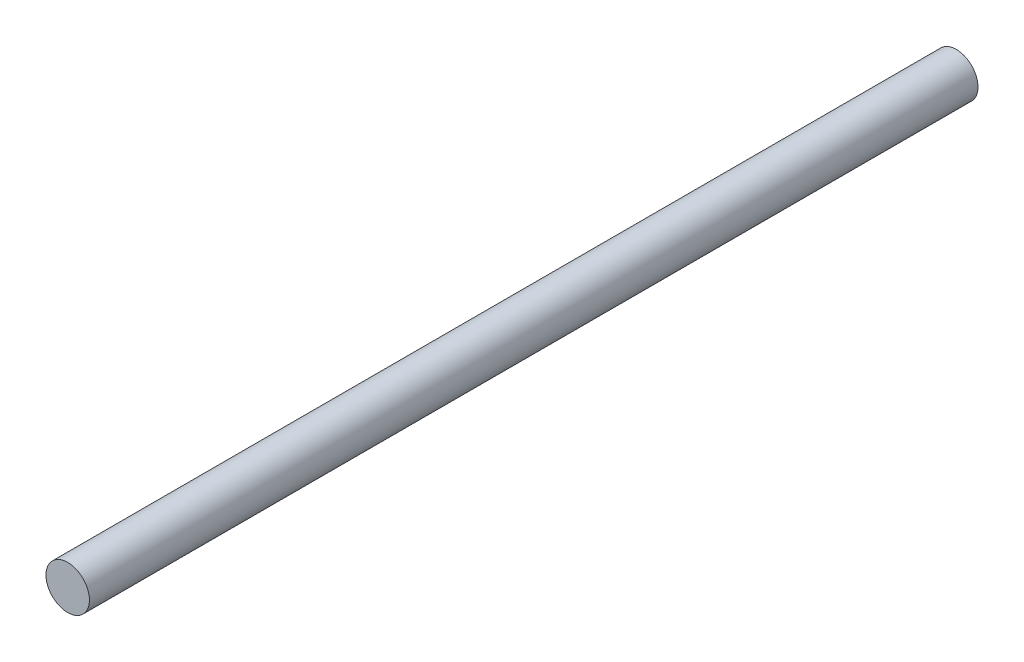
from build123d import *

# Parameters (mm, degrees)
SKETCH1_R           = 4
BOSS_EXTRUDE1_DEPTH = 163.5


with BuildPart() as part:
    # Sketch1 → Boss-Extrude1 (new body)
    with BuildSketch(Plane.XY):
        Circle(SKETCH1_R)
    extrude(amount=BOSS_EXTRUDE1_DEPTH)


solid = part.part
